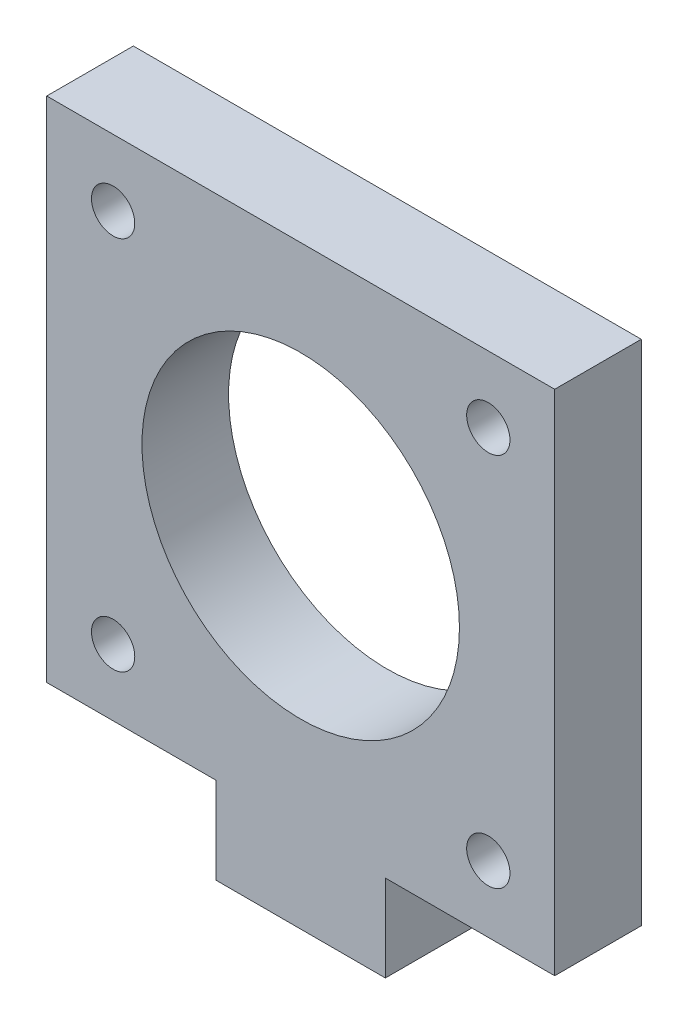
from build123d import *

# Parameters (mm, degrees)
SKETCH1_R           = 1.5
SKETCH1_R_2         = 1.499633597
SKETCH1_R_3         = 11
BOSS_EXTRUDE1_DEPTH = 6


with BuildPart() as part:
    # Sketch1 → Boss-Extrude1 (new body)
    with BuildSketch(Plane.XY):
        Polygon((342.916937196, 225.798518154), (342.916937196, 260.998518154), (307.716937196, 260.998518154), (307.716937196, 225.798518154), (319.450270529, 225.798518154), (319.450270529, 219.798518154), (331.183603862, 219.798518154), (331.183603862, 225.798518154), align=None)
        with Locations((338.316937196, 230.398518154)):
            Circle(SKETCH1_R, mode=Mode.SUBTRACT)
        with Locations((338.316937196, 256.398518154)):
            Circle(SKETCH1_R, mode=Mode.SUBTRACT)
        with Locations((312.316937196, 256.398518154)):
            Circle(SKETCH1_R, mode=Mode.SUBTRACT)
        with Locations((312.316937196, 230.398518154)):
            Circle(SKETCH1_R_2, mode=Mode.SUBTRACT)
        with Locations((325.316937196, 243.398518154)):
            Circle(SKETCH1_R_3, mode=Mode.SUBTRACT)
    extrude(amount=BOSS_EXTRUDE1_DEPTH)


solid = part.part
